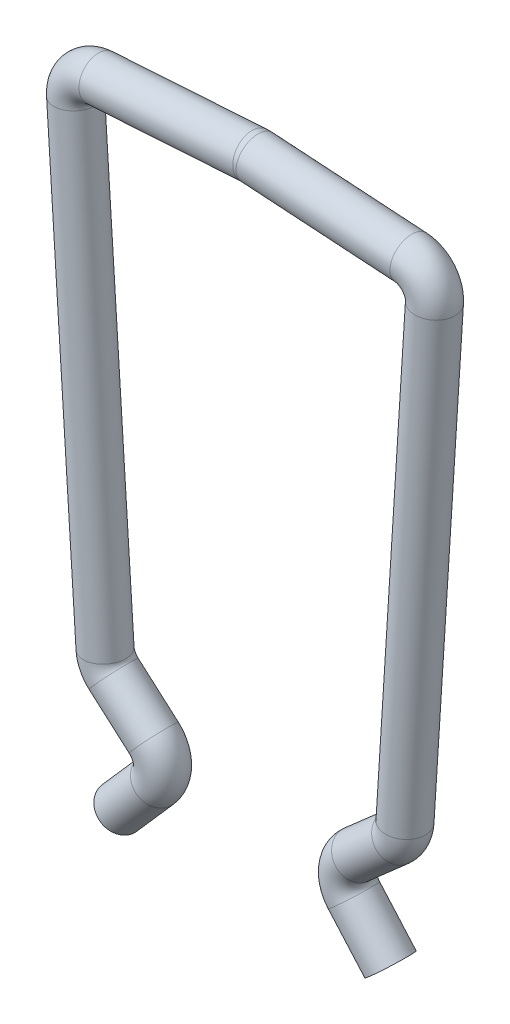
from build123d import *

# Parameters (mm, degrees)
SKETCH2_R = 0.4


with BuildPart() as part:
    # Sweep2: sweep along a path in Sketch1
    with BuildLine(Plane.XY) as sweep2_path:
        Line((-2.336808688, -12.175709903), (-1.623951591, -11.36452769))
        ThreePointArc((-1.623951591, -11.36452769), (-1.401867222, -10.712480492), (-1.705896853, -10.094376134))
        Line((-1.705896853, -10.094376134), (-2.485919755, -9.408901463))
        ThreePointArc((-2.485919755, -9.408901463), (-2.509663341, -9.377876145), (-2.519707362, -9.340121067))
        Line((-2.519707362, -9.340121067), (-3.093670387, -0.299696983))
        ThreePointArc((-3.093670387, -0.299696983), (-3.068954021, -0.227310998), (-3.000309548, -0.193568358))
        Line((-3.000309548, -0.193568358), (-0.006438228, -0.00041537))
        ThreePointArc((-0.006438228, -0.00041537), (0, -0.0002079), (0.006438228, -0.00041537))
        Line((0.006438228, -0.00041537), (3.000309548, -0.193568358))
        ThreePointArc((3.000309548, -0.193568358), (3.068954021, -0.227310998), (3.093670387, -0.299696983))
        Line((3.093670387, -0.299696983), (2.519707362, -9.340121067))
        ThreePointArc((2.519707362, -9.340121067), (2.509663341, -9.377876145), (2.485919755, -9.408901463))
        Line((2.485919755, -9.408901463), (1.705896853, -10.094376134))
        ThreePointArc((1.705896853, -10.094376134), (1.401867222, -10.712480492), (1.623951591, -11.36452769))
        Line((1.623951591, -11.36452769), (2.336808688, -12.175709903))
    # Sketch2 → Sweep2 (sweep)
    with BuildSketch(Plane(origin=(-2.336808688, -12.175709903, 0), x_dir=(-0.7511648984498777, 0.6601146077286768, 0), z_dir=(-0.6601146077286769, -0.7511648984498778, 0))):
        with Locations((0.4, 0)):
            Circle(SKETCH2_R)
    sweep(path=sweep2_path.line)


solid = part.part
